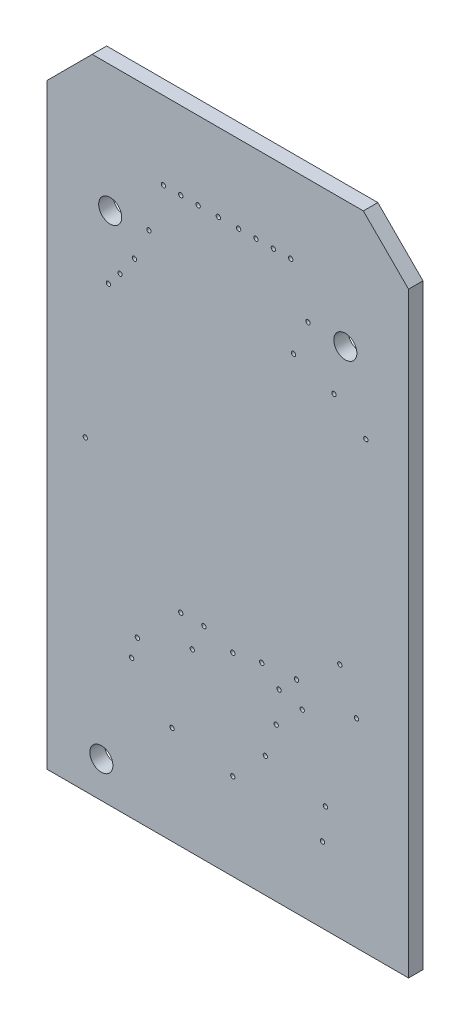
from build123d import *

# Parameters (mm, degrees)
BOARD_OUTLINE_DEPTH = 0.508
SKETCH2_R           = 0.0762
NPTH_DEPTH          = 1.508
SKETCH3_R           = 0.405
PTH_DEPTH           = 1.508


with BuildPart() as part:
    # Sketch1 → Board_Outline (new body)
    with BuildSketch(Plane.XY):
        Polygon((0, 0), (0, 20.955), (1.5875, 22.5425), (11.1125, 22.5425), (12.7, 20.955), (12.7, 0), align=None)
    extrude(amount=BOARD_OUTLINE_DEPTH)

    # Sketch2 → NPTH (cut, through all)
    with BuildSketch(Plane.XY):
        with Locations((10.287, 8.3312)):
            Circle(SKETCH2_R)
        with Locations((7.6708, 4.2418)):
            Circle(SKETCH2_R)
        with Locations((6.731, 19.812)):
            Circle(SKETCH2_R)
        with Locations((11.2014, 15.6464)):
            Circle(SKETCH2_R)
        with Locations((5.3086, 19.812)):
            Circle(SKETCH2_R)
        with Locations((2.5654, 16.3576)):
            Circle(SKETCH2_R)
        with Locations((4.699, 19.812)):
            Circle(SKETCH2_R)
        with Locations((3.0734, 17.0688)):
            Circle(SKETCH2_R)
        with Locations((4.0894, 19.812)):
            Circle(SKETCH2_R)
        with Locations((3.5814, 18.1864)):
            Circle(SKETCH2_R)
        with Locations((8.5598, 19.812)):
            Circle(SKETCH2_R)
        with Locations((8.6614, 16.9672)):
            Circle(SKETCH2_R)
        with Locations((7.9502, 19.812)):
            Circle(SKETCH2_R)
        with Locations((9.1694, 18.1864)):
            Circle(SKETCH2_R)
        with Locations((7.3406, 19.812)):
            Circle(SKETCH2_R)
        with Locations((10.0838, 16.4592)):
            Circle(SKETCH2_R)
        with Locations((6.0198, 19.812)):
            Circle(SKETCH2_R)
        with Locations((2.159, 15.8496)):
            Circle(SKETCH2_R)
        with Locations((4.699, 7.112)):
            Circle(SKETCH2_R)
        with Locations((3.175, 5.588)):
            Circle(SKETCH2_R)
        with Locations((4.3942, 3.4544)):
            Circle(SKETCH2_R)
        with Locations((2.9718, 4.8768)):
            Circle(SKETCH2_R)
        with Locations((5.5118, 7.112)):
            Circle(SKETCH2_R)
        with Locations((6.5278, 6.8072)):
            Circle(SKETCH2_R)
        with Locations((6.5278, 3.048)):
            Circle(SKETCH2_R)
        with Locations((9.6774, 2.6416)):
            Circle(SKETCH2_R)
        with Locations((7.5438, 7.0104)):
            Circle(SKETCH2_R)
        with Locations((5.1054, 6.1976)):
            Circle(SKETCH2_R)
        with Locations((9.779, 3.7592)):
            Circle(SKETCH2_R)
        with Locations((8.9662, 6.2992)):
            Circle(SKETCH2_R)
        with Locations((8.763, 7.112)):
            Circle(SKETCH2_R)
        with Locations((8.1534, 6.5024)):
            Circle(SKETCH2_R)
        with Locations((8.0518, 5.3848)):
            Circle(SKETCH2_R)
        with Locations((1.3462, 10.7696)):
            Circle(SKETCH2_R)
        with Locations((10.8712, 6.985)):
            Circle(SKETCH2_R)
    extrude(amount=NPTH_DEPTH, mode=Mode.SUBTRACT)

    # Sketch3 → PTH (cut, through all)
    with BuildSketch(Plane.XY):
        with Locations((2.22, 18.1)):
            Circle(SKETCH3_R)
        with Locations((10.48, 18.1)):
            Circle(SKETCH3_R)
        with Locations((1.91, 1.27)):
            Circle(SKETCH3_R)
    extrude(amount=PTH_DEPTH, mode=Mode.SUBTRACT)


solid = part.part
